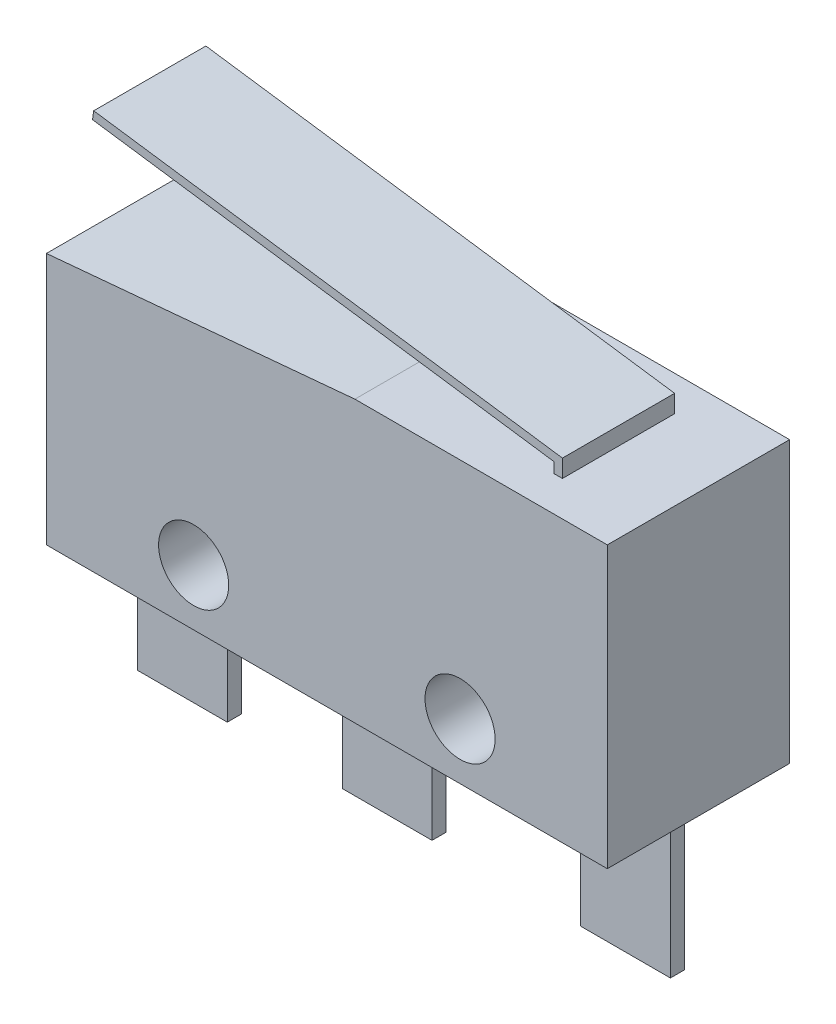
from build123d import *

# Parameters (mm, degrees)
SKETCH1_W                   = 20
SKETCH1_H                   = 10
BOSS_BODY_DEPTH             = 3.25
CUT_TOP_ANGLE_DEPTH         = 7.5
SKETCH3_W                   = 2
SKETCH3_H                   = 0.5
BOSS_BUTTON_DEPTH           = 1
BOSS_BUTTON_ROUND_TOP_DEPTH = 1
SKETCH5_R                   = 1.25
CUT_EXTRUDE2_DEPTH          = 7.5
SKETCH6_W                   = 3.2
SKETCH6_H                   = 5
BOSS_EXTRUDE4_DEPTH         = 0.5
EXTRUDE_THIN1_DEPTH         = 2


with BuildPart() as part:
    # Sketch1 → Boss-Body (new body, symmetric)
    with BuildSketch(Plane.XY):
        with Locations((0, 5)):
            Rectangle(SKETCH1_W, SKETCH1_H)
    extrude(amount=BOSS_BODY_DEPTH, both=True)

    # Sketch2 → Cut-Top Angle (cut, through all)
    with BuildSketch(Plane.XY.offset(3.25)):
        Polygon((1, 10), (-10, 9), (-10, 10), align=None)
    extrude(amount=-CUT_TOP_ANGLE_DEPTH, mode=Mode.SUBTRACT)

    # Sketch3 → Boss-Button (add, symmetric)
    with BuildSketch(Plane.XY):
        with Locations((3, 10.25)):
            Rectangle(SKETCH3_W, SKETCH3_H)
    extrude(amount=BOSS_BUTTON_DEPTH, both=True)

    # Sketch4 → Boss-Button Round Top (add, symmetric)
    with BuildSketch(Plane.XY):
        with BuildLine():
            Line((2, 10.5), (4, 10.5))
            ThreePointArc((4, 10.5), (3, 11.1), (2, 10.5))
        make_face()
    extrude(amount=BOSS_BUTTON_ROUND_TOP_DEPTH, both=True)

    # Sketch5 → Cut-Extrude2 (cut, through all)
    with BuildSketch(Plane.XY.offset(3.25)):
        with Locations((-4.75, 2)):
            Circle(SKETCH5_R)
        with Locations((4.75, 2)):
            Circle(SKETCH5_R)
    extrude(amount=-CUT_EXTRUDE2_DEPTH, mode=Mode.SUBTRACT)

    # Sketch6 → Boss-Extrude4 (add)
    with BuildSketch(Plane.XY):
        with Locations((-7.9, -2.5)):
            Rectangle(SKETCH6_W, SKETCH6_H)
        with Locations((7.9, -2.5)):
            Rectangle(SKETCH6_W, SKETCH6_H)
        with Locations((-0.6, -2.5)):
            Rectangle(SKETCH6_W, SKETCH6_H)
    extrude(amount=BOSS_EXTRUDE4_DEPTH)

    # Sketch7 → Extrude-Thin1 (add, symmetric)
    with BuildSketch(Plane.XY):
        Polygon((7.15, 10), (7.15, 10.630243429), (-9.563285177, 12.998516388), (-9.605374729, 12.701483612), (6.85, 10.369756571), (6.85, 10), align=None)
    extrude(amount=EXTRUDE_THIN1_DEPTH, both=True)


solid = part.part
